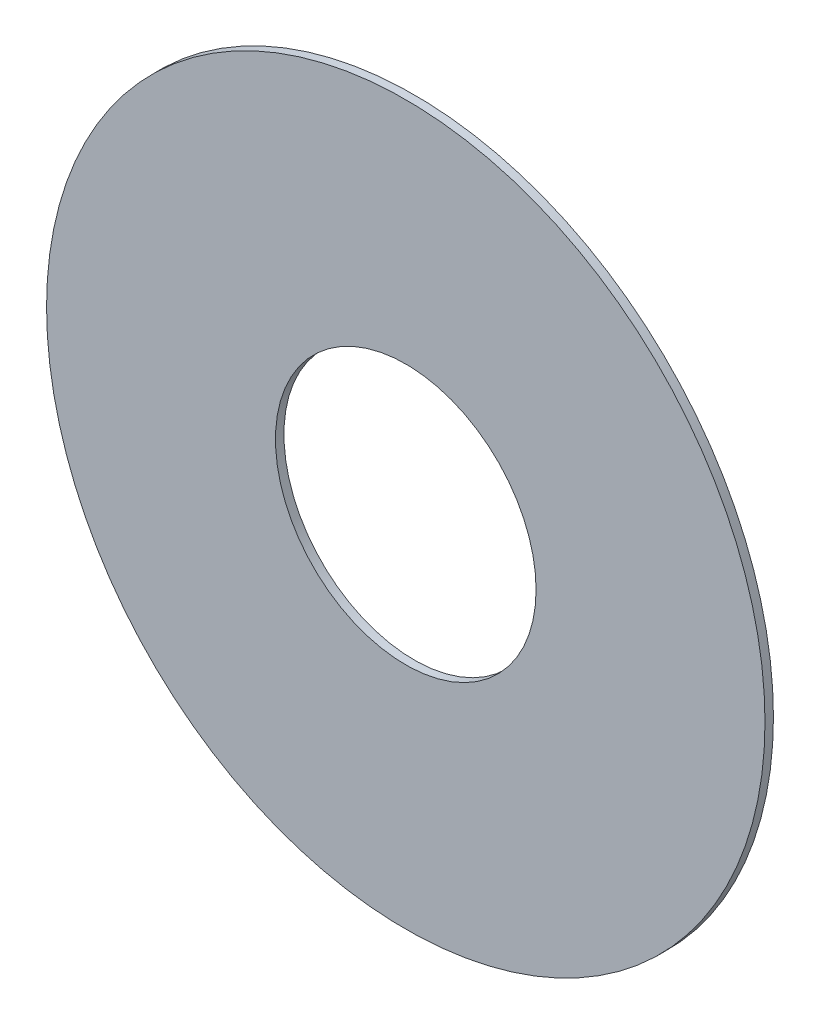
from build123d import *

# Parameters (mm, degrees)
SKETCH1_R           = 25.5
SKETCH1_R_2         = 9.25
BOSS_EXTRUDE1_DEPTH = 0.6


with BuildPart() as part:
    # Sketch1 → Boss-Extrude1 (new body)
    with BuildSketch(Plane.XY):
        Circle(SKETCH1_R)
        Circle(SKETCH1_R_2, mode=Mode.SUBTRACT)
    extrude(amount=BOSS_EXTRUDE1_DEPTH)


solid = part.part
